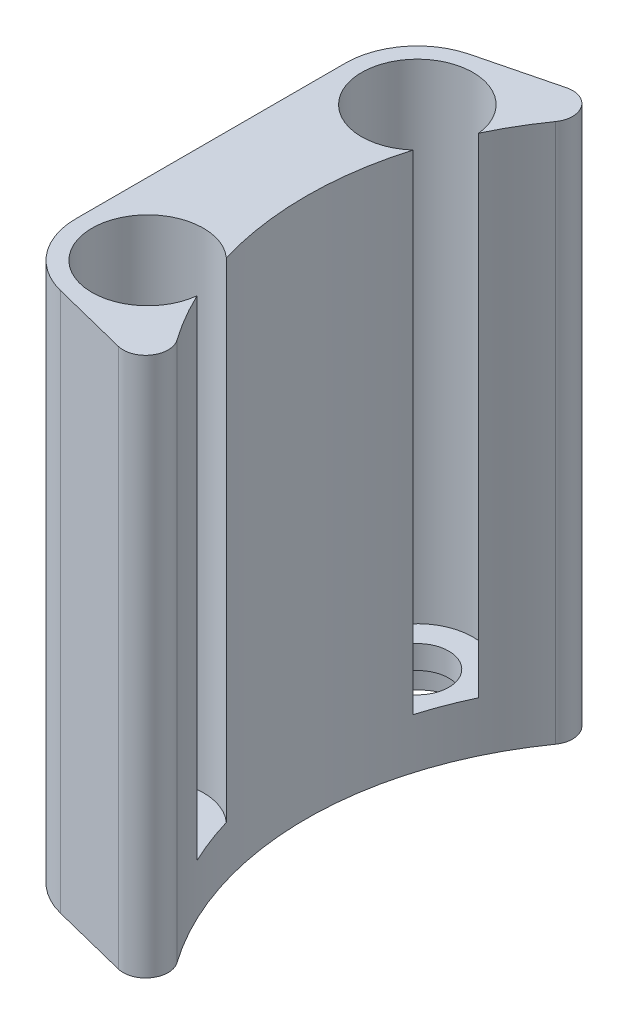
from build123d import *

# Parameters (mm, degrees)
BOSS_EXTRU_1_DEPTH      = 54.4
ESQUISSE2_R             = 6.2
ENL_V_MAT_EXTRU_1_DEPTH = 55.4
BOSS_EXTRU_2_DEPTH      = 54.4
ESQUISSE4_R             = 3.5
BOSS_EXTRU_3_DEPTH      = 2.6
ESQUISSE5_R             = 5.1
BOSS_EXTRU_4_DEPTH      = 3


with BuildPart() as part:
    # Esquisse1 → Boss.-Extru.1 (new body)
    with BuildSketch(Plane(origin=(0, 0, 0), x_dir=(1, 0, 0), z_dir=(0, 1, 0))):
        with BuildLine():
            ThreePointArc((-33.897137082, 23.942307692), (-41.5, 0), (-33.897137082, -23.942307692))
            ThreePointArc((-33.897137082, -23.942307692), (-30.41283318, -24.54199621), (-29.813144663, -21.057692308))
            ThreePointArc((-29.813144663, -21.057692308), (-36.5, 0), (-29.813144663, 21.057692308))
            ThreePointArc((-29.813144663, 21.057692308), (-30.41283318, 24.54199621), (-33.897137082, 23.942307692))
        make_face()
    extrude(amount=BOSS_EXTRU_1_DEPTH)

    # Esquisse2 → Enlèv. mat.-Extru.1 (cut, through all)
    with BuildSketch(Plane(origin=(0, 54.4, 0), x_dir=(1, 0, 0), z_dir=(0, 1, 0))):
        with Locations((-39.130938787, 15)):
            Circle(ESQUISSE2_R)
        with Locations((-39.130938787, -15)):
            Circle(ESQUISSE2_R)
    extrude(amount=-ENL_V_MAT_EXTRU_1_DEPTH, mode=Mode.SUBTRACT)

    # Esquisse3 → Boss.-Extru.2 (add)
    with BuildSketch(Plane.XZ):
        with BuildLine():
            Line((-47.130938787, 15), (-47.130938787, -15))
            ThreePointArc((-47.130938787, -15), (-45.439748727, -19.919239489), (-41.081209501, -22.758636745))
            Line((-41.081209501, -22.758636745), (-32.46460047, -24.924573983))
            ThreePointArc((-32.46460047, -24.924573983), (-29.793288851, -23.913777296), (-29.813144663, -21.057692308))
            ThreePointArc((-29.813144663, -21.057692308), (-31.505533615, -18.429632433), (-32.966857258, -15.666407455))
            ThreePointArc((-32.966857258, -15.666407455), (-44.920174268, -17.219178351), (-34.991734648, -10.384050575))
            ThreePointArc((-34.991734648, -10.384050575), (-36.5, 0), (-34.991734648, 10.384050575))
            ThreePointArc((-34.991734648, 10.384050575), (-44.920174268, 17.219178351), (-32.966857258, 15.666407455))
            ThreePointArc((-32.966857258, 15.666407455), (-31.505533615, 18.429632433), (-29.813144663, 21.057692308))
            ThreePointArc((-29.813144663, 21.057692308), (-29.793288851, 23.913777296), (-32.46460047, 24.924573983))
            Line((-32.46460047, 24.924573983), (-41.081209501, 22.758636745))
            ThreePointArc((-41.081209501, 22.758636745), (-45.439748727, 19.919239489), (-47.130938787, 15))
        make_face()
    extrude(amount=-BOSS_EXTRU_2_DEPTH)

    # Esquisse4 → Boss.-Extru.3 (add)
    with BuildSketch(Plane.XZ):
        with BuildLine():
            Line((-47.130938787, 15), (-47.130938787, -15))
            ThreePointArc((-47.130938787, -15), (-45.439748727, -19.919239489), (-41.081209501, -22.758636745))
            Line((-41.081209501, -22.758636745), (-32.46460047, -24.924573983))
            ThreePointArc((-32.46460047, -24.924573983), (-29.793288851, -23.913777296), (-29.813144663, -21.057692308))
            ThreePointArc((-29.813144663, -21.057692308), (-36.5, 0), (-29.813144663, 21.057692308))
            ThreePointArc((-29.813144663, 21.057692308), (-29.793288851, 23.913777296), (-32.46460047, 24.924573983))
            Line((-32.46460047, 24.924573983), (-41.081209501, 22.758636745))
            ThreePointArc((-41.081209501, 22.758636745), (-45.439748727, 19.919239489), (-47.130938787, 15))
        make_face()
        with Locations((-39.130938787, 15)):
            Circle(ESQUISSE4_R, mode=Mode.SUBTRACT)
        with Locations((-39.130938787, -15)):
            Circle(ESQUISSE4_R, mode=Mode.SUBTRACT)
    extrude(amount=BOSS_EXTRU_3_DEPTH)

    # Esquisse5 → Boss.-Extru.4 (add)
    with BuildSketch(Plane.XZ.offset(2.6)):
        with BuildLine():
            Line((-32.46460047, 24.924573983), (-41.081209501, 22.758636745))
            ThreePointArc((-41.081209501, 22.758636745), (-45.439748727, 19.919239489), (-47.130938787, 15))
            Line((-47.130938787, 15), (-47.130938787, -15))
            ThreePointArc((-47.130938787, -15), (-45.439748727, -19.919239489), (-41.081209501, -22.758636745))
            Line((-41.081209501, -22.758636745), (-32.46460047, -24.924573983))
            ThreePointArc((-32.46460047, -24.924573983), (-29.793288851, -23.913777296), (-29.813144663, -21.057692308))
            ThreePointArc((-29.813144663, -21.057692308), (-36.5, 0), (-29.813144663, 21.057692308))
            ThreePointArc((-29.813144663, 21.057692308), (-29.793288851, 23.913777296), (-32.46460047, 24.924573983))
        make_face()
        with Locations((-39.130938787, 15)):
            Circle(ESQUISSE5_R, mode=Mode.SUBTRACT)
        with Locations((-39.130938787, -15)):
            Circle(ESQUISSE5_R, mode=Mode.SUBTRACT)
    extrude(amount=BOSS_EXTRU_4_DEPTH)


solid = part.part
